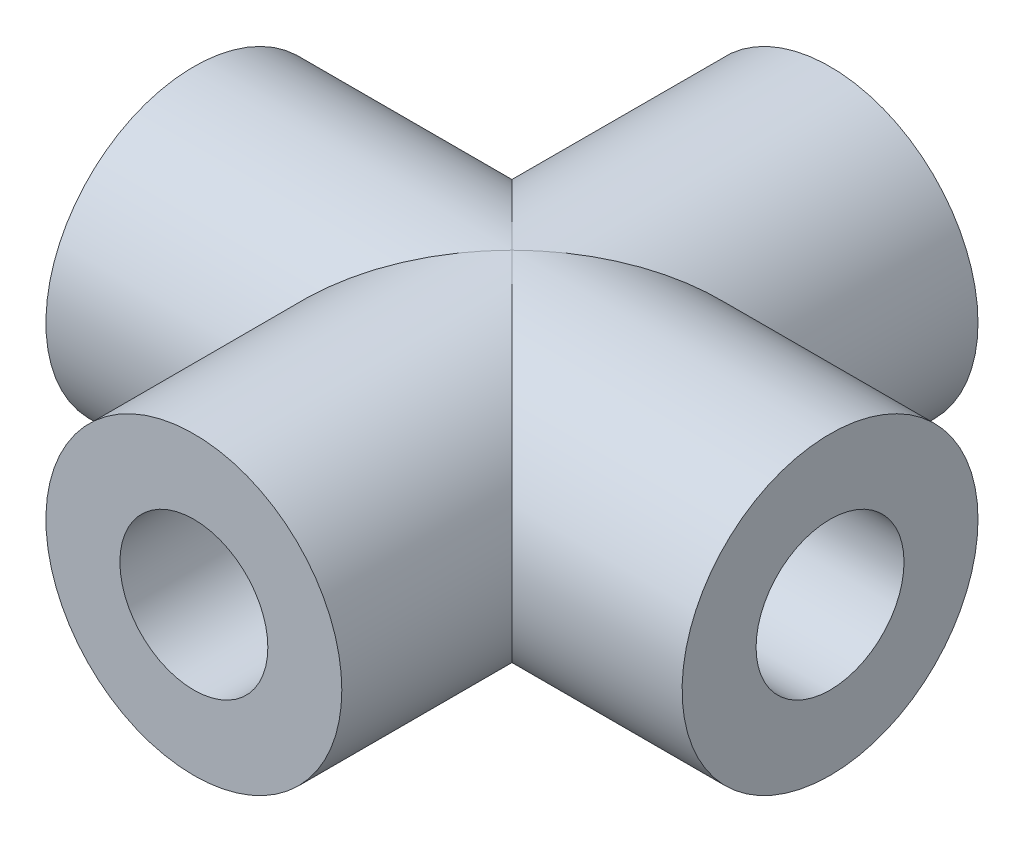
from build123d import *

# Parameters (mm, degrees)
SKETCH1_R           = 12.7
SKETCH1_R_2         = 6.35
BOSS_EXTRUDE3_DEPTH = 27.305
SKETCH2_R           = 12.7
SKETCH2_R_2         = 6.35
BOSS_EXTRUDE4_DEPTH = 27.305


with BuildPart() as part:
    # Sketch1 → Boss-Extrude3 (new body, symmetric)
    with BuildSketch(Plane.XY):
        Circle(SKETCH1_R)
        Circle(SKETCH1_R_2, mode=Mode.SUBTRACT)
    extrude(amount=BOSS_EXTRUDE3_DEPTH, both=True)

    # Sketch2 → Boss-Extrude4 (add, symmetric)
    with BuildSketch(Plane(origin=(0, 0, 0), x_dir=(0, 0, -1), z_dir=(1, 0, 0))):
        Circle(SKETCH2_R)
        Circle(SKETCH2_R_2, mode=Mode.SUBTRACT)
    extrude(amount=BOSS_EXTRUDE4_DEPTH, both=True)


solid = part.part
